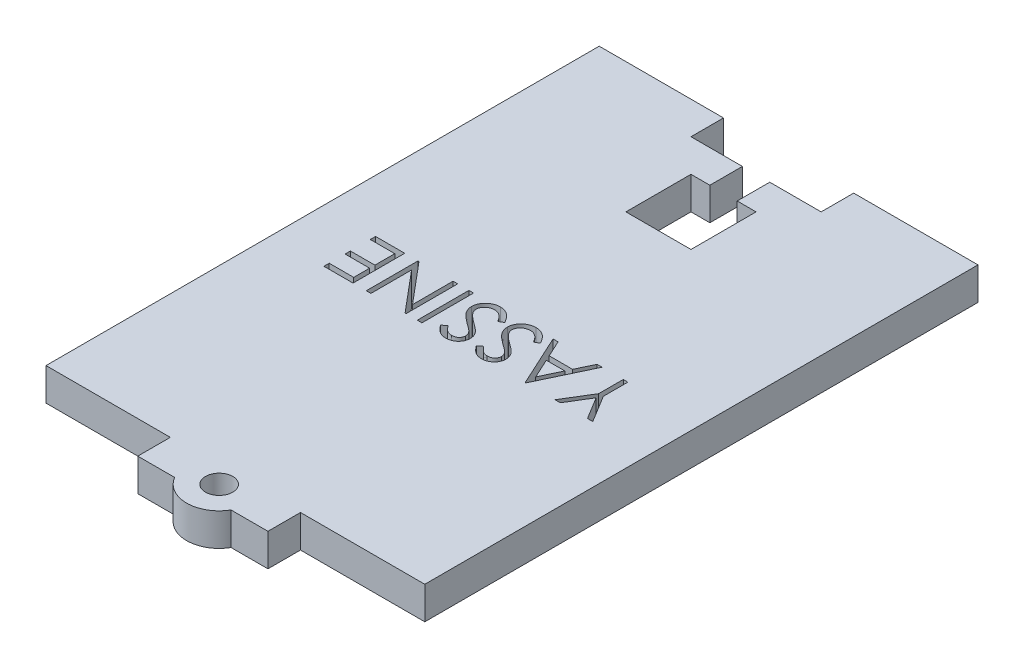
from build123d import *

# Parameters (mm, degrees)
BOSS_EXTRUDE1_DEPTH = 80
SKETCH2_W           = 19.1
SKETCH2_H           = 5
BOSS_EXTRUDE2_DEPTH = 5
SKETCH3_W           = 20
SKETCH3_H           = 5
BOSS_EXTRUDE3_DEPTH = 5
BOSS_EXTRUDE4_DEPTH = 5
SKETCH5_R           = 2.1
CUT_EXTRUDE1_DEPTH  = 5
SKETCH6_W           = 0.712339744
SKETCH6_H           = 7.9375
CUT_EXTRUDE2_DEPTH  = 5


with BuildPart() as part:
    # Sketch1 → Boss-Extrude1 (new body)
    with BuildSketch(Plane.XY):
        Polygon((122.435354573, 70.556903049), (103.335354573, 70.556903049), (83.335354573, 70.556903049), (64.235354573, 70.556903049), (64.235354573, 75.556903049), (83.335354573, 75.556903049), (103.335354573, 75.556903049), (122.435354573, 75.556903049), align=None)
    extrude(amount=BOSS_EXTRUDE1_DEPTH)

    # Sketch2 → Boss-Extrude2 (add)
    with BuildSketch(Plane(origin=(0, 0, 0), x_dir=(-1, 0, 0), z_dir=(0, 0, -1))):
        with Locations((-112.885354573, 73.056903049)):
            Rectangle(SKETCH2_W, SKETCH2_H)
        with Locations((-73.785354573, 73.056903049)):
            Rectangle(SKETCH2_W, SKETCH2_H)
    extrude(amount=BOSS_EXTRUDE2_DEPTH)

    # Sketch3 → Boss-Extrude3 (add)
    with BuildSketch(Plane.XY.offset(80)):
        with Locations((93.335354573, 73.056903049)):
            Rectangle(SKETCH3_W, SKETCH3_H)
    extrude(amount=BOSS_EXTRUDE3_DEPTH)

    # Sketch4 → Boss-Extrude4 (add)
    with BuildSketch(Plane(origin=(0, 75.556903049, 0), x_dir=(1, 0, 0), z_dir=(0, 1, 0))):
        with BuildLine():
            Line((97.665481592, -85), (89.005227555, -85))
            ThreePointArc((89.005227555, -85), (93.335354573, -87.5), (97.665481592, -85))
        make_face()
    extrude(amount=-BOSS_EXTRUDE4_DEPTH)

    # Sketch5 → Cut-Extrude1 (cut)
    with BuildSketch(Plane(origin=(0, 75.556903049, 0), x_dir=(1, 0, 0), z_dir=(0, 1, 0))):
        with Locations((93.335354573, -82.5)):
            Circle(SKETCH5_R)
        Polygon((91.235354573, 0), (91.235354573, -5), (88.335354573, -5), (88.335354573, -15), (98.335354573, -15), (98.335354573, -5), (95.435354573, -5), (95.435354573, 0), align=None)
    extrude(amount=-CUT_EXTRUDE1_DEPTH, mode=Mode.SUBTRACT)

    # Sketch6 → Cut-Extrude2 (cut)
    with BuildSketch(Plane(origin=(0, 75.556903049, 0), x_dir=(1, 0, 0), z_dir=(0, 1, 0))):
        Polygon((76.84977765, -45.4375), (72.372213548, -45.4375), (72.372213548, -44.623397436), (76.137437907, -44.623397436), (76.137437907, -42.181089744), (72.372213548, -42.181089744), (72.372213548, -41.366987179), (76.137437907, -41.366987179), (76.137437907, -38.314102564), (72.372213548, -38.314102564), (72.372213548, -37.5), (76.84977765, -37.5), align=None)
        Polygon((84.990803291, -37.5), (84.990803291, -45.4375), (84.841339149, -45.4375), (79.597373804, -39.190216847), (79.597373804, -45.4375), (78.885034061, -45.4375), (78.885034061, -37.5), (79.047218556, -37.5), (84.278463548, -43.732972756), (84.278463548, -37.5), align=None)
        with Locations((87.076941112, -41.46875)):
            Rectangle(SKETCH6_W, SKETCH6_H)
        with BuildLine():
            Line((93.742405856, -39.03121244), (93.071407258, -39.43349359))
            add(Edge.make_bspline(
                [(93.071407258, -39.43349359), (93.008999827, -39.329026145), (92.889429598, -39.128870553), (92.68996848, -38.858410354), (92.483292056, -38.628535463), (92.267869817, -38.440583157), (92.045016685, -38.292608003), (91.813277849, -38.187827942), (91.573434242, -38.122477426), (91.410207897, -38.11453973), (91.328718957, -38.110576923)],
                knots=[0, 0, 0, 0, 0.0003649, 0.000699135, 0.001006425, 0.001290478, 0.001554646, 0.001805858, 0.002050756, 0.002294909, 0.002294909, 0.002294909, 0.002294909], degree=3))
            add(Edge.make_bspline(
                [(91.328718957, -38.110576923), (91.259139623, -38.112561308), (91.12119843, -38.116495357), (90.917728889, -38.152769316), (90.721107521, -38.212113247), (90.533291251, -38.292561055), (90.359247284, -38.39144647), (90.204203861, -38.508059433), (90.073202929, -38.642771432), (89.964900689, -38.79072531), (89.880119903, -38.948832661), (89.819796354, -39.113199729), (89.781045814, -39.282779122), (89.7761328, -39.397776915), (89.773655856, -39.455754207)],
                knots=[0, 0, 0, 0, 0.000208593, 0.000413536, 0.000617768, 0.000823629, 0.001025188, 0.001216952, 0.001403604, 0.001586791, 0.001765344, 0.001939908, 0.002110822, 0.002284603, 0.002284603, 0.002284603, 0.002284603], degree=3))
            add(Edge.make_bspline(
                [(89.773655856, -39.455754207), (89.77692757, -39.521863549), (89.783553148, -39.655742176), (89.841944809, -39.853602318), (89.931106432, -40.05025334), (90.014908338, -40.171917577), (90.058273744, -40.234875801)],
                knots=[0, 0, 0, 0, 0.00019794, 0.00040085, 0.000614295, 0.0008432, 0.0008432, 0.0008432, 0.0008432], degree=3))
            add(Edge.make_bspline(
                [(90.058273744, -40.234875801), (90.093706626, -40.280437833), (90.168311881, -40.376370392), (90.298458007, -40.516661649), (90.446442351, -40.665204199), (90.616096284, -40.819033155), (90.804945885, -40.981295212), (91.015132179, -41.148981023), (91.244200912, -41.324591554), (91.405769761, -41.44057726), (91.489313408, -41.500550881)],
                knots=[0, 0, 0, 0, 0.000173081, 0.000364429, 0.000573555, 0.000802018, 0.001051229, 0.001320412, 0.001608539, 0.001917045, 0.001917045, 0.001917045, 0.001917045], degree=3))
            add(Edge.make_bspline(
                [(91.489313408, -41.500550881), (91.572813831, -41.560047186), (91.732460282, -41.67379959), (91.955894293, -41.842407221), (92.155425604, -41.997544871), (92.332070923, -42.13705153), (92.481260213, -42.267011771), (92.608447418, -42.380460452), (92.708940121, -42.483455602), (92.764861939, -42.550216712), (92.789969457, -42.580190805)],
                knots=[0, 0, 0, 0, 0.000307574, 0.000588058, 0.000839637, 0.001065859, 0.001263159, 0.001433116, 0.001577048, 0.001694323, 0.001694323, 0.001694323, 0.001694323], degree=3))
            add(Edge.make_bspline(
                [(92.789969457, -42.580190805), (92.825053098, -42.626913333), (92.894049786, -42.718799455), (92.985224358, -42.862378137), (93.062112122, -43.009074671), (93.123992397, -43.159420717), (93.174032631, -43.312286337), (93.208823431, -43.468819185), (93.230267745, -43.627956621), (93.232482881, -43.735026389), (93.233591753, -43.788624299)],
                knots=[0, 0, 0, 0, 0.000175237, 0.000344627, 0.000509624, 0.000671442, 0.000831847, 0.00099155, 0.001151892, 0.001312613, 0.001312613, 0.001312613, 0.001312613], degree=3))
            add(Edge.make_bspline(
                [(93.233591753, -43.788624299), (93.230644769, -43.872609733), (93.224813791, -44.038785472), (93.175093374, -44.28141171), (93.09754291, -44.513773046), (92.985345166, -44.730697959), (92.84675996, -44.931878939), (92.682259058, -45.11374721), (92.488761822, -45.270042643), (92.273349983, -45.402906255), (92.040318771, -45.508901783), (91.795416634, -45.586136766), (91.539744031, -45.63140118), (91.365997508, -45.637785965), (91.277837546, -45.641025641)],
                knots=[0, 0, 0, 0, 0.00025173, 0.000498079, 0.000739938, 0.000984562, 0.001228026, 0.001471141, 0.00171749, 0.001971659, 0.002228529, 0.002483496, 0.002740204, 0.003004629, 0.003004629, 0.003004629, 0.003004629], degree=3))
            add(Edge.make_bspline(
                [(91.277837546, -45.641025641), (91.184272912, -45.637903481), (90.998723055, -45.631711865), (90.725708153, -45.574566391), (90.461280907, -45.485777243), (90.249363222, -45.38003108), (90.083445401, -45.275554039), (89.95704828, -45.180150826), (89.828264696, -45.070555692), (89.698482243, -44.944446903), (89.566418637, -44.804350093), (89.432682507, -44.649078342), (89.296022221, -44.480031192), (89.208134408, -44.359320464), (89.163078932, -44.297438401)],
                knots=[0, 0, 0, 0, 0.000280394, 0.000556054, 0.00083311, 0.001115414, 0.001264072, 0.001420851, 0.001590039, 0.001771088, 0.001963431, 0.002167459, 0.002385735, 0.002615341, 0.002615341, 0.002615341, 0.002615341], degree=3))
            Line((89.163078932, -44.297438401), (89.807046781, -43.809294872))
            add(Edge.make_bspline(
                [(89.807046781, -43.809294872), (89.845928471, -43.859391767), (89.920805515, -43.955866673), (90.034529747, -44.090927324), (90.141555122, -44.214466869), (90.247808001, -44.321488108), (90.345098068, -44.420006399), (90.441201902, -44.502854258), (90.532406873, -44.57266185), (90.647107277, -44.647257231), (90.792777115, -44.719428814), (90.973931306, -44.781479172), (91.163367524, -44.819612798), (91.29197159, -44.824459531), (91.35733975, -44.826923077)],
                knots=[0, 0, 0, 0, 0.000190221, 0.000366322, 0.000529664, 0.000680341, 0.000818638, 0.000944884, 0.001060641, 0.001162961, 0.001354955, 0.001546534, 0.00173613, 0.001932118, 0.001932118, 0.001932118, 0.001932118], degree=3))
            add(Edge.make_bspline(
                [(91.35733975, -44.826923077), (91.439356928, -44.824220111), (91.597519329, -44.819007696), (91.821540505, -44.760582312), (92.024335573, -44.671750454), (92.198162867, -44.54365584), (92.341689367, -44.390942387), (92.446799321, -44.216783449), (92.509642715, -44.024431679), (92.517334637, -43.890317447), (92.521252009, -43.822015224)],
                knots=[0, 0, 0, 0, 0.000245491, 0.000473406, 0.000689745, 0.000906014, 0.001116412, 0.001314658, 0.001511772, 0.001716344, 0.001716344, 0.001716344, 0.001716344], degree=3))
            add(Edge.make_bspline(
                [(92.521252009, -43.822015224), (92.520267392, -43.779510477), (92.518284441, -43.693908873), (92.494642846, -43.567698322), (92.459362722, -43.442973561), (92.409354121, -43.319015992), (92.341391841, -43.192294174), (92.249087133, -43.063530395), (92.133580013, -42.929502033), (92.04493134, -42.842415739), (91.99812751, -42.796436799)],
                knots=[0, 0, 0, 0, 0.000127362, 0.000256499, 0.000383832, 0.000515815, 0.000656675, 0.000814162, 0.000990076, 0.001186837, 0.001186837, 0.001186837, 0.001186837], degree=3))
            add(Edge.make_bspline(
                [(91.99812751, -42.796436799), (91.980752612, -42.780931401), (91.939473831, -42.744094125), (91.864008785, -42.683786631), (91.764352797, -42.60939463), (91.643108162, -42.517348394), (91.498039323, -42.410574364), (91.32913033, -42.290437779), (91.138263997, -42.153038614), (91.002823223, -42.056977763), (90.931207939, -42.006184896)],
                knots=[0, 0, 0, 0, 6.9853e-05, 0.000165956, 0.000289663, 0.000442943, 0.000622625, 0.000830015, 0.001064761, 0.001328157, 0.001328157, 0.001328157, 0.001328157], degree=3))
            add(Edge.make_bspline(
                [(90.931207939, -42.006184896), (90.845061375, -41.943498197), (90.678250493, -41.822114092), (90.440901231, -41.639743417), (90.225698446, -41.461379462), (90.031870653, -41.28817285), (89.8575563, -41.121398693), (89.704512576, -40.959179844), (89.572045086, -40.802580113), (89.427486764, -40.603174795), (89.281525712, -40.356004604), (89.156376106, -40.053037997), (89.076758069, -39.74920197), (89.066417883, -39.54525153), (89.061316112, -39.444623898)],
                knots=[0, 0, 0, 0, 0.000319615, 0.00061889, 0.000897801, 0.001157932, 0.001398581, 0.001621301, 0.001826718, 0.002013411, 0.002359749, 0.002684854, 0.002994525, 0.003296118, 0.003296118, 0.003296118, 0.003296118], degree=3))
            add(Edge.make_bspline(
                [(89.061316112, -39.444623898), (89.062808755, -39.373463564), (89.065765055, -39.232524781), (89.099660134, -39.025552179), (89.149497757, -38.824621152), (89.223774739, -38.632232198), (89.316623123, -38.446241124), (89.429665289, -38.266974044), (89.566659522, -38.097376507), (89.71884368, -37.934154882), (89.887881774, -37.78653706), (90.066758592, -37.655056185), (90.254470139, -37.542479325), (90.453160046, -37.454036445), (90.659555351, -37.383289702), (90.874624889, -37.332580299), (91.098830802, -37.301351814), (91.251234098, -37.298118328), (91.328718957, -37.296474359)],
                knots=[0, 0, 0, 0, 0.000213279, 0.000422417, 0.000627582, 0.000833411, 0.001039627, 0.001250481, 0.001467765, 0.001692732, 0.001919195, 0.002139907, 0.002358062, 0.002574402, 0.002791121, 0.003011725, 0.003236372, 0.003468714, 0.003468714, 0.003468714, 0.003468714], degree=3))
            add(Edge.make_bspline(
                [(91.328718957, -37.296474359), (91.388667892, -37.297646929), (91.507810768, -37.299977303), (91.683564477, -37.320091224), (91.856090803, -37.349588545), (92.023223524, -37.394561236), (92.187043549, -37.450410312), (92.346091365, -37.518788913), (92.50075064, -37.600192086), (92.651212421, -37.694745747), (92.79885386, -37.803743916), (92.943079095, -37.929593789), (93.084610112, -38.071692972), (93.224034816, -38.229843719), (93.35806888, -38.406660151), (93.49008286, -38.599338165), (93.619389355, -38.808500232), (93.700634459, -38.955588439), (93.742405856, -39.03121244)],
                knots=[0, 0, 0, 0, 0.000179788, 0.000357311, 0.000530107, 0.000704433, 0.0008759, 0.001048981, 0.001223234, 0.0013997, 0.001581606, 0.001773218, 0.001973348, 0.002182909, 0.002405208, 0.002638517, 0.002883415, 0.003142567, 0.003142567, 0.003142567, 0.003142567], degree=3))
        make_face()
        with BuildLine():
            Line((99.237598163, -39.03121244), (98.566599565, -39.43349359))
            add(Edge.make_bspline(
                [(98.566599565, -39.43349359), (98.504192135, -39.329026145), (98.384621905, -39.128870553), (98.185160787, -38.858410354), (97.978484364, -38.628535463), (97.763062125, -38.440583157), (97.540208993, -38.292608003), (97.308470157, -38.187827942), (97.06862655, -38.122477426), (96.905400205, -38.11453973), (96.823911264, -38.110576923)],
                knots=[0, 0, 0, 0, 0.0003649, 0.000699135, 0.001006425, 0.001290478, 0.001554646, 0.001805858, 0.002050756, 0.002294909, 0.002294909, 0.002294909, 0.002294909], degree=3))
            add(Edge.make_bspline(
                [(96.823911264, -38.110576923), (96.75433193, -38.112561308), (96.616390737, -38.116495357), (96.412921196, -38.152769316), (96.216299828, -38.212113247), (96.028483559, -38.292561055), (95.854439592, -38.39144647), (95.699396169, -38.508059433), (95.568395236, -38.642771432), (95.460092996, -38.79072531), (95.375312211, -38.948832661), (95.314988662, -39.113199729), (95.276238121, -39.282779122), (95.271325108, -39.397776915), (95.268848163, -39.455754207)],
                knots=[0, 0, 0, 0, 0.000208593, 0.000413536, 0.000617768, 0.000823629, 0.001025188, 0.001216952, 0.001403604, 0.001586791, 0.001765344, 0.001939908, 0.002110822, 0.002284603, 0.002284603, 0.002284603, 0.002284603], degree=3))
            add(Edge.make_bspline(
                [(95.268848163, -39.455754207), (95.272119878, -39.521863549), (95.278745456, -39.655742176), (95.337137117, -39.853602318), (95.42629874, -40.05025334), (95.510100645, -40.171917577), (95.553466052, -40.234875801)],
                knots=[0, 0, 0, 0, 0.00019794, 0.00040085, 0.000614295, 0.0008432, 0.0008432, 0.0008432, 0.0008432], degree=3))
            add(Edge.make_bspline(
                [(95.553466052, -40.234875801), (95.588898933, -40.280437833), (95.663504189, -40.376370392), (95.793650315, -40.516661649), (95.941634659, -40.665204199), (96.111288591, -40.819033155), (96.300138193, -40.981295212), (96.510324486, -41.148981023), (96.739393219, -41.324591554), (96.900962068, -41.44057726), (96.984505715, -41.500550881)],
                knots=[0, 0, 0, 0, 0.000173081, 0.000364429, 0.000573555, 0.000802018, 0.001051229, 0.001320412, 0.001608539, 0.001917045, 0.001917045, 0.001917045, 0.001917045], degree=3))
            add(Edge.make_bspline(
                [(96.984505715, -41.500550881), (97.068006139, -41.560047186), (97.227652589, -41.67379959), (97.451086601, -41.842407221), (97.650617911, -41.997544871), (97.827263231, -42.13705153), (97.976452521, -42.267011771), (98.103639726, -42.380460452), (98.204132428, -42.483455602), (98.260054247, -42.550216712), (98.285161765, -42.580190805)],
                knots=[0, 0, 0, 0, 0.000307574, 0.000588058, 0.000839637, 0.001065859, 0.001263159, 0.001433116, 0.001577048, 0.001694323, 0.001694323, 0.001694323, 0.001694323], degree=3))
            add(Edge.make_bspline(
                [(98.285161765, -42.580190805), (98.320245406, -42.626913333), (98.389242094, -42.718799455), (98.480416665, -42.862378137), (98.55730443, -43.009074671), (98.619184705, -43.159420717), (98.669224939, -43.312286337), (98.704015739, -43.468819185), (98.725460052, -43.627956621), (98.727675189, -43.735026389), (98.728784061, -43.788624299)],
                knots=[0, 0, 0, 0, 0.000175237, 0.000344627, 0.000509624, 0.000671442, 0.000831847, 0.00099155, 0.001151892, 0.001312613, 0.001312613, 0.001312613, 0.001312613], degree=3))
            add(Edge.make_bspline(
                [(98.728784061, -43.788624299), (98.725837077, -43.872609733), (98.720006098, -44.038785472), (98.670285682, -44.28141171), (98.592735218, -44.513773046), (98.480537473, -44.730697959), (98.341952268, -44.931878939), (98.177451366, -45.11374721), (97.98395413, -45.270042643), (97.768542291, -45.402906255), (97.535511079, -45.508901783), (97.290608942, -45.586136766), (97.034936339, -45.63140118), (96.861189816, -45.637785965), (96.773029854, -45.641025641)],
                knots=[0, 0, 0, 0, 0.00025173, 0.000498079, 0.000739938, 0.000984562, 0.001228026, 0.001471141, 0.00171749, 0.001971659, 0.002228529, 0.002483496, 0.002740204, 0.003004629, 0.003004629, 0.003004629, 0.003004629], degree=3))
            add(Edge.make_bspline(
                [(96.773029854, -45.641025641), (96.67946522, -45.637903481), (96.493915363, -45.631711865), (96.220900461, -45.574566391), (95.956473215, -45.485777243), (95.744555529, -45.38003108), (95.578637709, -45.275554039), (95.452240588, -45.180150826), (95.323457004, -45.070555692), (95.19367455, -44.944446903), (95.061610944, -44.804350093), (94.927874815, -44.649078342), (94.791214529, -44.480031192), (94.703326715, -44.359320464), (94.65827124, -44.297438401)],
                knots=[0, 0, 0, 0, 0.000280394, 0.000556054, 0.00083311, 0.001115414, 0.001264072, 0.001420851, 0.001590039, 0.001771088, 0.001963431, 0.002167459, 0.002385735, 0.002615341, 0.002615341, 0.002615341, 0.002615341], degree=3))
            Line((94.65827124, -44.297438401), (95.302239089, -43.809294872))
            add(Edge.make_bspline(
                [(95.302239089, -43.809294872), (95.341120779, -43.859391767), (95.415997823, -43.955866673), (95.529722054, -44.090927324), (95.63674743, -44.214466869), (95.743000309, -44.321488108), (95.840290376, -44.420006399), (95.93639421, -44.502854258), (96.02759918, -44.57266185), (96.142299585, -44.647257231), (96.287969422, -44.719428814), (96.469123614, -44.781479172), (96.658559832, -44.819612798), (96.787163898, -44.824459531), (96.852532057, -44.826923077)],
                knots=[0, 0, 0, 0, 0.000190221, 0.000366322, 0.000529664, 0.000680341, 0.000818638, 0.000944884, 0.001060641, 0.001162961, 0.001354955, 0.001546534, 0.00173613, 0.001932118, 0.001932118, 0.001932118, 0.001932118], degree=3))
            add(Edge.make_bspline(
                [(96.852532057, -44.826923077), (96.934549235, -44.824220111), (97.092711637, -44.819007696), (97.316732813, -44.760582312), (97.519527881, -44.671750454), (97.693355174, -44.54365584), (97.836881675, -44.390942387), (97.941991629, -44.216783449), (98.004835023, -44.024431679), (98.012526945, -43.890317447), (98.016444317, -43.822015224)],
                knots=[0, 0, 0, 0, 0.000245491, 0.000473406, 0.000689745, 0.000906014, 0.001116412, 0.001314658, 0.001511772, 0.001716344, 0.001716344, 0.001716344, 0.001716344], degree=3))
            add(Edge.make_bspline(
                [(98.016444317, -43.822015224), (98.0154597, -43.779510477), (98.013476748, -43.693908873), (97.989835153, -43.567698322), (97.954555029, -43.442973561), (97.904546429, -43.319015992), (97.836584149, -43.192294174), (97.744279441, -43.063530395), (97.628772321, -42.929502033), (97.540123647, -42.842415739), (97.493319818, -42.796436799)],
                knots=[0, 0, 0, 0, 0.000127362, 0.000256499, 0.000383832, 0.000515815, 0.000656675, 0.000814162, 0.000990076, 0.001186837, 0.001186837, 0.001186837, 0.001186837], degree=3))
            add(Edge.make_bspline(
                [(97.493319818, -42.796436799), (97.47594492, -42.780931401), (97.434666139, -42.744094125), (97.359201093, -42.683786631), (97.259545104, -42.60939463), (97.138300469, -42.517348394), (96.993231631, -42.410574364), (96.824322638, -42.290437779), (96.633456304, -42.153038614), (96.498015531, -42.056977763), (96.426400247, -42.006184896)],
                knots=[0, 0, 0, 0, 6.9853e-05, 0.000165956, 0.000289663, 0.000442943, 0.000622625, 0.000830015, 0.001064761, 0.001328157, 0.001328157, 0.001328157, 0.001328157], degree=3))
            add(Edge.make_bspline(
                [(96.426400247, -42.006184896), (96.340253683, -41.943498197), (96.173442801, -41.822114092), (95.936093539, -41.639743417), (95.720890754, -41.461379462), (95.527062961, -41.28817285), (95.352748607, -41.121398693), (95.199704884, -40.959179844), (95.067237394, -40.802580113), (94.922679072, -40.603174795), (94.77671802, -40.356004604), (94.651568414, -40.053037997), (94.571950377, -39.74920197), (94.561610191, -39.54525153), (94.55650842, -39.444623898)],
                knots=[0, 0, 0, 0, 0.000319615, 0.00061889, 0.000897801, 0.001157932, 0.001398581, 0.001621301, 0.001826718, 0.002013411, 0.002359749, 0.002684854, 0.002994525, 0.003296118, 0.003296118, 0.003296118, 0.003296118], degree=3))
            add(Edge.make_bspline(
                [(94.55650842, -39.444623898), (94.558001063, -39.373463564), (94.560957362, -39.232524781), (94.594852442, -39.025552179), (94.644690065, -38.824621152), (94.718967046, -38.632232198), (94.811815431, -38.446241124), (94.924857596, -38.266974044), (95.06185183, -38.097376507), (95.214035987, -37.934154882), (95.383074082, -37.78653706), (95.5619509, -37.655056185), (95.749662447, -37.542479325), (95.948352354, -37.454036445), (96.154747659, -37.383289702), (96.369817197, -37.332580299), (96.59402311, -37.301351814), (96.746426406, -37.298118328), (96.823911264, -37.296474359)],
                knots=[0, 0, 0, 0, 0.000213279, 0.000422417, 0.000627582, 0.000833411, 0.001039627, 0.001250481, 0.001467765, 0.001692732, 0.001919195, 0.002139907, 0.002358062, 0.002574402, 0.002791121, 0.003011725, 0.003236372, 0.003468714, 0.003468714, 0.003468714, 0.003468714], degree=3))
            add(Edge.make_bspline(
                [(96.823911264, -37.296474359), (96.8838602, -37.297646929), (97.003003075, -37.299977303), (97.178756784, -37.320091224), (97.351283111, -37.349588545), (97.518415831, -37.394561236), (97.682235857, -37.450410312), (97.841283673, -37.518788913), (97.995942947, -37.600192086), (98.146404728, -37.694745747), (98.294046168, -37.803743916), (98.438271403, -37.929593789), (98.57980242, -38.071692972), (98.719227123, -38.229843719), (98.853261187, -38.406660151), (98.985275168, -38.599338165), (99.114581663, -38.808500232), (99.195826767, -38.955588439), (99.237598163, -39.03121244)],
                knots=[0, 0, 0, 0, 0.000179788, 0.000357311, 0.000530107, 0.000704433, 0.0008759, 0.001048981, 0.001223234, 0.0013997, 0.001581606, 0.001773218, 0.001973348, 0.002182909, 0.002405208, 0.002638517, 0.002883415, 0.003142567, 0.003142567, 0.003142567, 0.003142567], degree=3))
        make_face()
        Polygon((103.308110984, -45.4375), (99.644649445, -37.5), (100.419000908, -37.5), (101.592453432, -40.044070513), (105.190723163, -40.044070513), (106.397566613, -37.5), (107.175098163, -37.5), (103.409873804, -45.4375), align=None)
        Polygon((103.366942614, -43.890387119), (104.804342454, -40.858173077), (101.967703832, -40.858173077), align=None, mode=Mode.SUBTRACT)
        Polygon((113.687918676, -45.4375), (112.872226068, -45.4375), (110.786088247, -42.026855469), (108.703130515, -45.4375), (107.887437907, -45.4375), (110.43150842, -41.273174579), (110.43150842, -37.5), (111.143848163, -37.5), (111.143848163, -41.273174579), align=None)
    extrude(amount=-CUT_EXTRUDE2_DEPTH, mode=Mode.SUBTRACT)


solid = part.part
